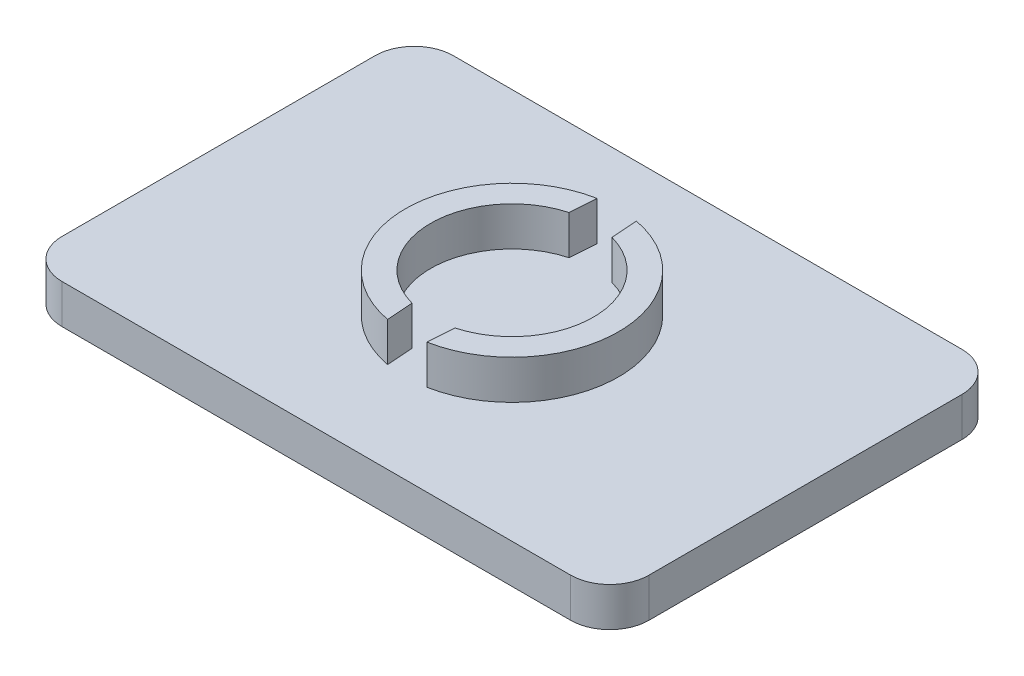
from build123d import *

# Parameters (mm, degrees)
SKETCH1_W           = 76.2
SKETCH1_H           = 50.8
BOSS_EXTRUDE1_DEPTH = 5.08
FILLET1_R           = 5.08
BOSS_EXTRUDE2_DEPTH = 5.08


with BuildPart() as part:
    # Sketch1 → Boss-Extrude1 (new body)
    with BuildSketch(Plane(origin=(0, 0, 0), x_dir=(1, 0, 0), z_dir=(0, 1, 0))):
        Rectangle(SKETCH1_W, SKETCH1_H)
    extrude(amount=BOSS_EXTRUDE1_DEPTH)

    # Fillet1
    fillet1_edges = [part.edges().sort_by_distance(p)[0] for p in [
        (38.1, 2.54, -25.4),
        (38.1, 2.54, 25.4),
        (-38.1, 2.54, 25.4),
        (-38.1, 2.54, -25.4),
    ]]
    fillet(fillet1_edges, radius=FILLET1_R)

    # Sketch2 → Boss-Extrude2 (add)
    with BuildSketch(Plane(origin=(0, 5.08, 0), x_dir=(1, 0, 0), z_dir=(0, 1, 0))):
        with BuildLine():
            Line((2.794, 10.190953103), (2.54, 13.605741995))
            ThreePointArc((2.54, 13.605741995), (13.840802551, 0), (2.54, -13.605741995))
            Line((2.54, -13.605741995), (2.794, -10.190953103))
            ThreePointArc((2.794, -10.190953103), (10.567022341, 0), (2.794, 10.190953103))
        make_face()
        with BuildLine():
            Line((-2.794, 10.190953103), (-2.54, 13.605741995))
            ThreePointArc((-2.54, 13.605741995), (-13.840802551, 0), (-2.54, -13.605741995))
            Line((-2.54, -13.605741995), (-2.794, -10.190953103))
            ThreePointArc((-2.794, -10.190953103), (-10.567022341, 0), (-2.794, 10.190953103))
        make_face()
    extrude(amount=BOSS_EXTRUDE2_DEPTH)


solid = part.part
